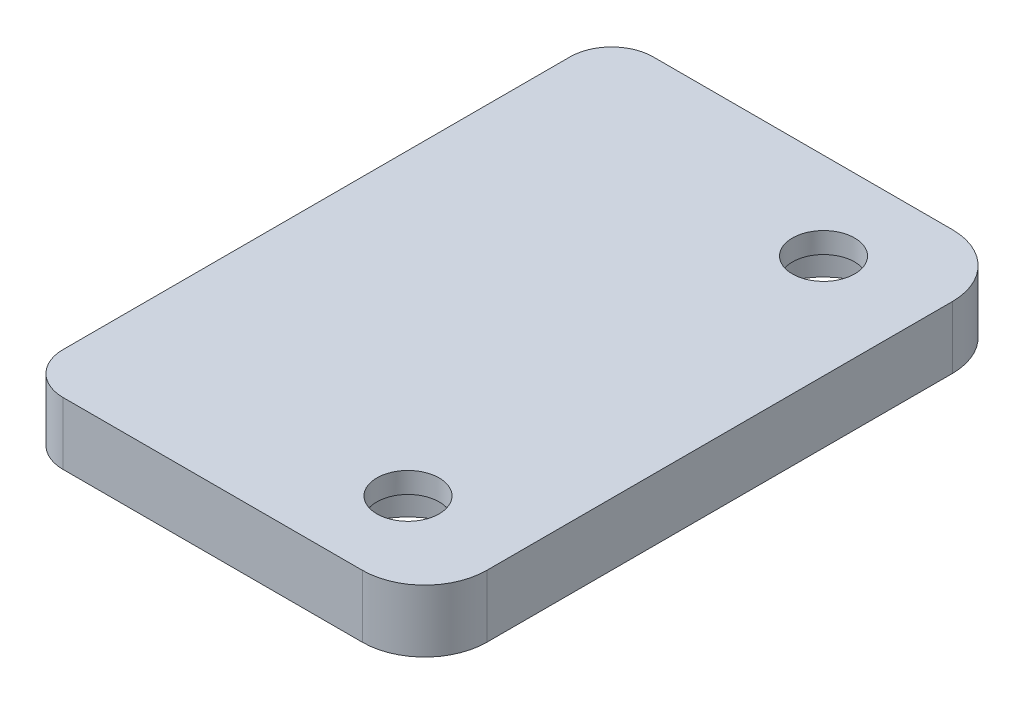
from build123d import *

# Parameters (mm, degrees)
SKETCH1_W           = 19.4
SKETCH1_H           = 28.4
BOSS_EXTRUDE1_DEPTH = 3
FILLET1_R           = 3
FILLET2_R           = 2
SKETCH2_R           = 1.5
CUT_EXTRUDE1_DEPTH  = 4
SKETCH4_R           = 3
CUT_EXTRUDE2_DEPTH  = 2


with BuildPart() as part:
    # Sketch1 → Boss-Extrude1 (new body)
    with BuildSketch(Plane(origin=(0, 0, 0), x_dir=(1, 0, 0), z_dir=(0, 1, 0))):
        Rectangle(SKETCH1_W, SKETCH1_H)
    extrude(amount=BOSS_EXTRUDE1_DEPTH)

    # Fillet1
    fillet1_edges = [part.edges().sort_by_distance(p)[0] for p in [
        (9.7, 1.5, -14.2),
        (9.7, 1.5, 14.2),
    ]]
    fillet(fillet1_edges, radius=FILLET1_R)

    # Fillet2
    fillet2_edges = [part.edges().sort_by_distance(p)[0] for p in [
        (-9.7, 1.5, -14.2),
        (-9.7, 1.5, 14.2),
    ]]
    fillet(fillet2_edges, radius=FILLET2_R)

    # Sketch2 → Cut-Extrude1 (cut, through all)
    with BuildSketch(Plane(origin=(0, 3, 0), x_dir=(1, 0, 0), z_dir=(0, 1, 0))):
        with Locations((4.7, 10)):
            Circle(SKETCH2_R)
        with Locations((4.7, -10)):
            Circle(SKETCH2_R)
    extrude(amount=-CUT_EXTRUDE1_DEPTH, mode=Mode.SUBTRACT)

    # Sketch4 → Cut-Extrude2 (cut)
    with BuildSketch(Plane.XZ):
        with Locations((4.7, 10)):
            Circle(SKETCH4_R)
        with Locations((4.7, -10)):
            Circle(SKETCH4_R)
    extrude(amount=-CUT_EXTRUDE2_DEPTH, mode=Mode.SUBTRACT)


solid = part.part
